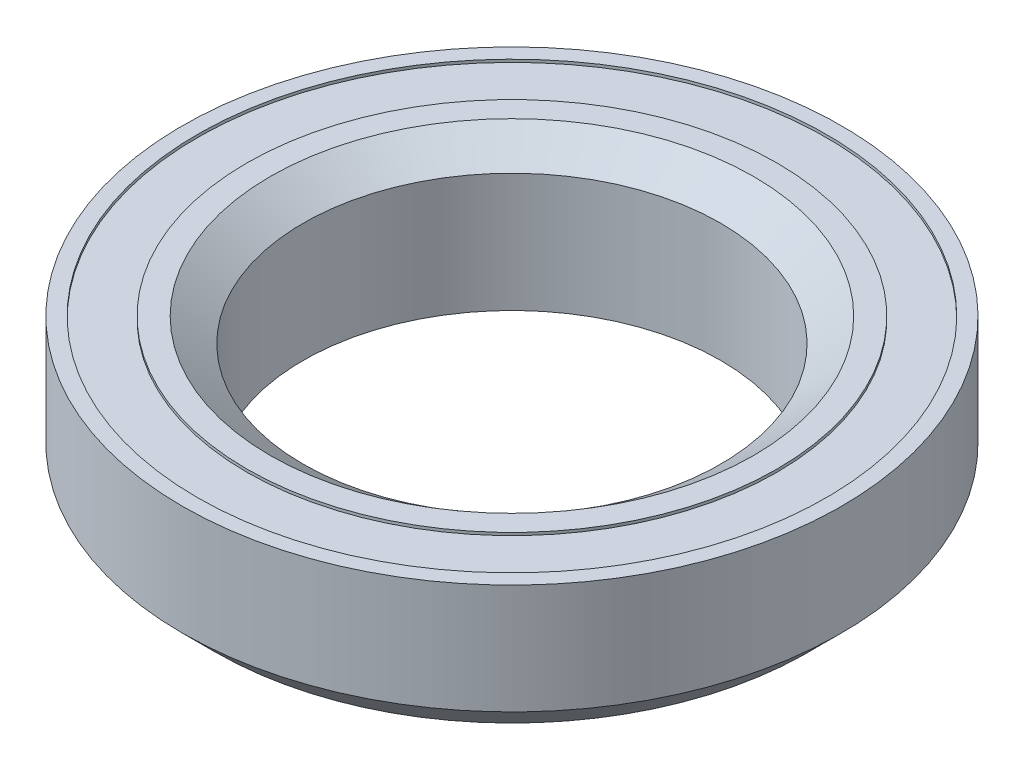
from build123d import *

# Parameters (mm, degrees)
SKETCH1_R           = 15
BOSS_EXTRUDE1_DEPTH = 6.5
SKETCH2_R           = 9.5
CUT_EXTRUDE1_DEPTH  = 7.5
CHAMFER1_SIZE       = 1.5
CHAMFER2_SIZE       = 1.5
CHAMFER2_SIZE2      = 1.089813792
SKETCH3_R           = 12.8905
SKETCH3_R_2         = 10.223184072
CUT_EXTRUDE2_DEPTH  = 0.127
SKETCH4_R           = 14.316034094
SKETCH4_R_2         = 12.065
CUT_EXTRUDE3_DEPTH  = 0.127


with BuildPart() as part:
    # Sketch1 → Boss-Extrude1 (new body)
    with BuildSketch(Plane(origin=(0, 0, 0), x_dir=(1, 0, 0), z_dir=(0, 1, 0))):
        Circle(SKETCH1_R)
    extrude(amount=BOSS_EXTRUDE1_DEPTH)

    # Sketch2 → Cut-Extrude1 (cut, through all)
    with BuildSketch(Plane(origin=(0, 6.5, 0), x_dir=(1, 0, 0), z_dir=(0, 1, 0))):
        Circle(SKETCH2_R)
    extrude(amount=-CUT_EXTRUDE1_DEPTH, mode=Mode.SUBTRACT)

    # Chamfer1
    chamfer1_edges = [part.edges().sort_by_distance(p)[0] for p in [
        (-15, 0, 0),
    ]]
    chamfer(chamfer1_edges, length=CHAMFER1_SIZE)

    # Chamfer2
    chamfer2_edges = [part.edges().sort_by_distance(p)[0] for p in [
        (-9.5, 6.5, 0),
    ]]
    chamfer2_side = [part.faces().sort_by_distance(p)[0] for p in [
        (-14.575735931, 6.5, 0),
    ]]
    chamfer(chamfer2_edges, length=CHAMFER2_SIZE, length2=CHAMFER2_SIZE2, reference=chamfer2_side[0])

    # Sketch3 → Cut-Extrude2 (cut)
    with BuildSketch(Plane.XZ):
        Circle(SKETCH3_R)
        Circle(SKETCH3_R_2, mode=Mode.SUBTRACT)
    extrude(amount=-CUT_EXTRUDE2_DEPTH, mode=Mode.SUBTRACT)

    # Sketch4 → Cut-Extrude3 (cut)
    with BuildSketch(Plane(origin=(0, 6.5, 0), x_dir=(1, 0, 0), z_dir=(0, 1, 0))):
        Circle(SKETCH4_R)
        Circle(SKETCH4_R_2, mode=Mode.SUBTRACT)
    extrude(amount=-CUT_EXTRUDE3_DEPTH, mode=Mode.SUBTRACT)


solid = part.part
